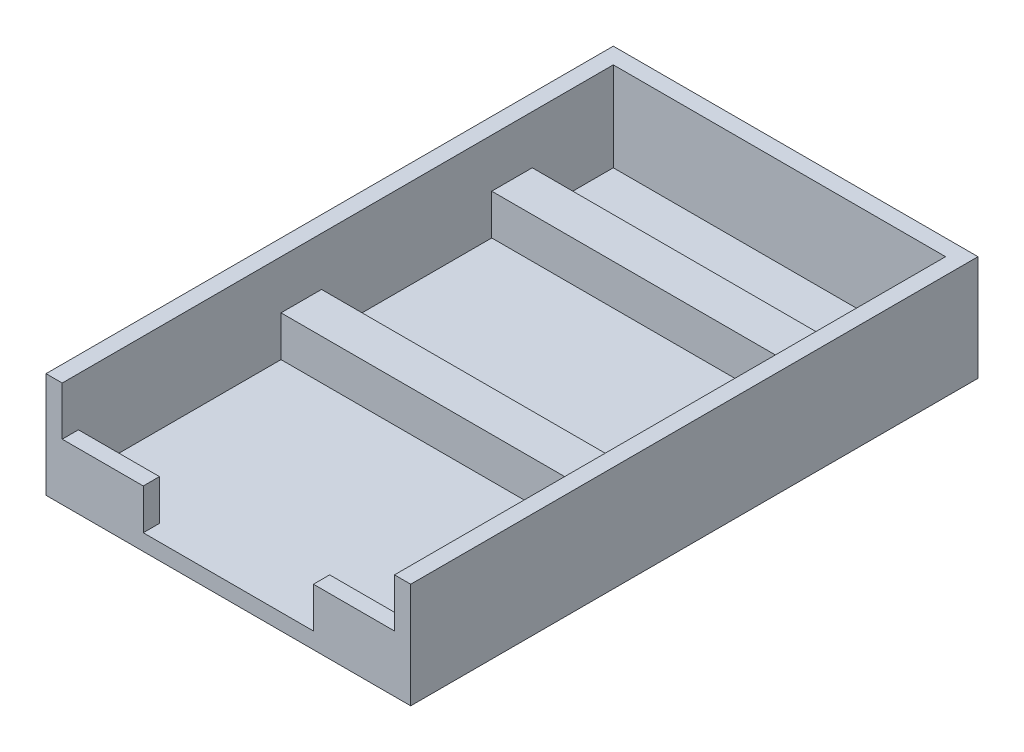
from build123d import *

# Parameters (mm, degrees)
SKETCH1_W               = 45
SKETCH1_H               = 70
BOSS_EXTRUDE1_DEPTH     = 10
SKETCH2_W               = 41
SKETCH2_H               = 66
CUT_EXTRUDE1_DEPTH      = 8
SKETCH7_W               = 41
SKETCH7_H               = 3
CUT_EXTRUDE2_DEPTH      = 1
CUT_EXTRUDE2_DEPTH_BACK = 81
SKETCH8_W               = 21
SKETCH8_H               = 5
CUT_EXTRUDE3_DEPTH      = 42
SKETCH9_W               = 41
SKETCH9_H               = 5
BOSS_EXTRUDE3_DEPTH     = 5
SKETCH10_W              = 41
SKETCH10_H              = 5
BOSS_EXTRUDE4_DEPTH     = 5
SKETCH13_W              = 2
SKETCH13_H              = 70
BOSS_EXTRUDE5_DEPTH     = 3
SKETCH14_W              = 41
SKETCH14_H              = 2
BOSS_EXTRUDE6_DEPTH     = 3
SKETCH15_W              = 2
SKETCH15_H              = 70
BOSS_EXTRUDE7_DEPTH     = 3


with BuildPart() as part:
    # Sketch1 → Boss-Extrude1 (new body)
    with BuildSketch(Plane(origin=(0, 0, 0), x_dir=(1, 0, 0), z_dir=(0, 1, 0))):
        Rectangle(SKETCH1_W, SKETCH1_H)
    extrude(amount=BOSS_EXTRUDE1_DEPTH)

    # Sketch2 → Cut-Extrude1 (cut)
    with BuildSketch(Plane(origin=(0, 10, 0), x_dir=(1, 0, 0), z_dir=(0, 1, 0))):
        Rectangle(SKETCH2_W, SKETCH2_H)
    extrude(amount=-CUT_EXTRUDE1_DEPTH, mode=Mode.SUBTRACT)

    # Sketch7 → Cut-Extrude2 (cut, two sides)
    with BuildSketch(Plane(origin=(0, 0, 33), x_dir=(-1, 0, 0), z_dir=(0, 0, -1))) as cut_extrude2_sk:
        with Locations((0, 8.5)):
            Rectangle(SKETCH7_W, SKETCH7_H)
    extrude(amount=CUT_EXTRUDE2_DEPTH, mode=Mode.SUBTRACT)
    extrude(cut_extrude2_sk.sketch, amount=-CUT_EXTRUDE2_DEPTH_BACK, mode=Mode.SUBTRACT)

    # Sketch8 → Cut-Extrude3 (cut)
    with BuildSketch(Plane(origin=(0, 0, 33), x_dir=(-1, 0, 0), z_dir=(0, 0, -1))):
        with Locations((0, 4.5)):
            Rectangle(SKETCH8_W, SKETCH8_H)
    extrude(amount=-CUT_EXTRUDE3_DEPTH, mode=Mode.SUBTRACT)

    # Sketch9 → Boss-Extrude3 (add)
    with BuildSketch(Plane(origin=(0, 2, 0), x_dir=(1, 0, 0), z_dir=(0, 1, 0))):
        with Locations((0, -5.5)):
            Rectangle(SKETCH9_W, SKETCH9_H)
    extrude(amount=BOSS_EXTRUDE3_DEPTH)

    # Sketch10 → Boss-Extrude4 (add)
    with BuildSketch(Plane(origin=(0, 2, 0), x_dir=(1, 0, 0), z_dir=(0, 1, 0))):
        with Locations((0, 20.5)):
            Rectangle(SKETCH10_W, SKETCH10_H)
    extrude(amount=BOSS_EXTRUDE4_DEPTH)

    # Sketch13 → Boss-Extrude5 (add)
    with BuildSketch(Plane(origin=(0, 10, 0), x_dir=(1, 0, 0), z_dir=(0, 1, 0))):
        with Locations((-21.5, 0)):
            Rectangle(SKETCH13_W, SKETCH13_H)
    extrude(amount=BOSS_EXTRUDE5_DEPTH)

    # Sketch14 → Boss-Extrude6 (add)
    with BuildSketch(Plane(origin=(0, 10, 0), x_dir=(1, 0, 0), z_dir=(0, 1, 0))):
        with Locations((0, 34)):
            Rectangle(SKETCH14_W, SKETCH14_H)
    extrude(amount=BOSS_EXTRUDE6_DEPTH)

    # Sketch15 → Boss-Extrude7 (add)
    with BuildSketch(Plane(origin=(0, 10, 0), x_dir=(1, 0, 0), z_dir=(0, 1, 0))):
        with Locations((21.5, 0)):
            Rectangle(SKETCH15_W, SKETCH15_H)
    extrude(amount=BOSS_EXTRUDE7_DEPTH)


solid = part.part
